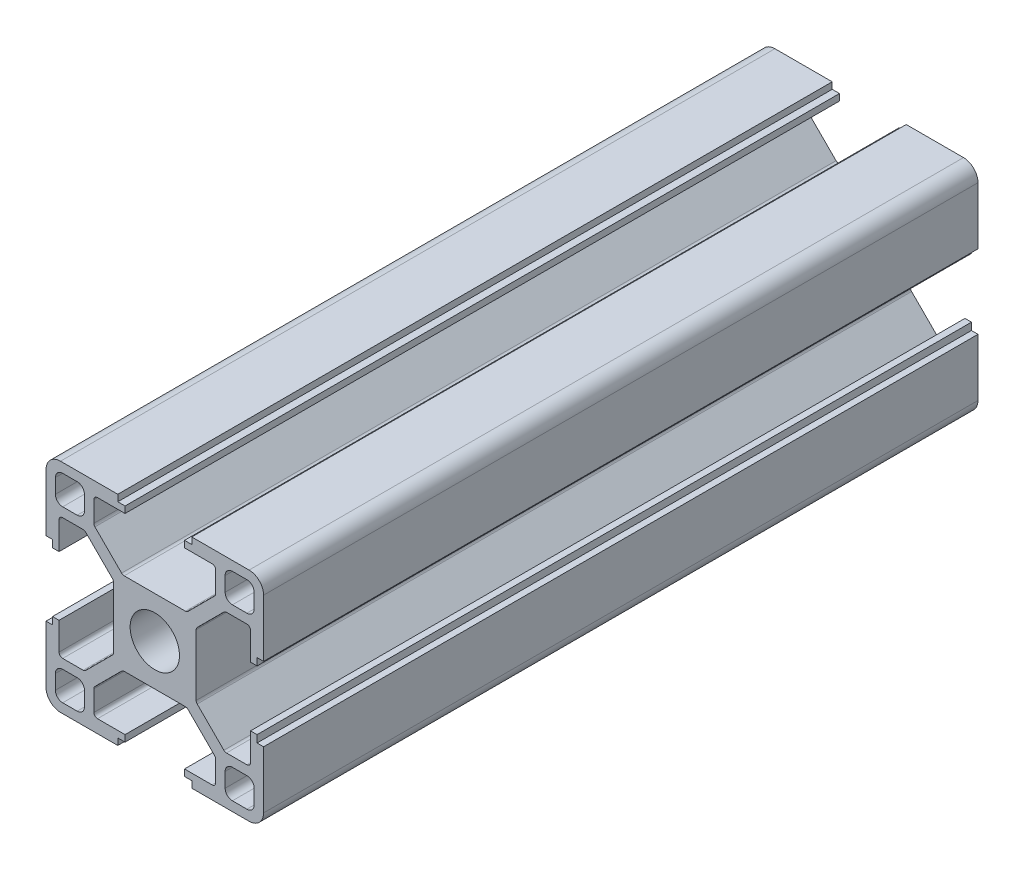
from build123d import *

# Parameters (mm, degrees)
SKETCH_1_W                       = 4
SKETCH_1_H                       = 4
EXTRUDE_1_DEPTH                  = 98.5
FILLET_1_R                       = 1
FILLET_2_R                       = 2
FILLET_3_R                       = 0.5
PATTERN_CIRCULAR_1_COUNT         = 4
FILLET_1_OF_PATTERN_CIRCULAR_1_R = 1
FILLET_2_OF_PATTERN_CIRCULAR_1_R = 2
FILLET_3_OF_PATTERN_CIRCULAR_1_R = 0.5
SKETCH_2_R                       = 3.4
CUT_EXTRUDE_1_DEPTH              = 99.5
SKETCH_3_R                       = 2.75
CUT_EXTRUDE_2_DEPTH              = 530


with BuildPart() as part:
    # 草图1 → 凸台-拉伸1 (new body)
    with BuildSketch(Plane.XY):
        Polygon((5.7, 0), (5.7, 4.427207794), (9.672792206, 8.4), (13.2, 8.4), (13.2, 4.1), (14.1, 4.1), (14.1, 5.1), (15, 5.1), (15, 15), (5.1, 15), (5.1, 14.1), (4.1, 14.1), (4.1, 13.2), (8.4, 13.2), (8.4, 9.672792206), (4.427207794, 5.7), (0, 5.7), (0, 0), align=None)
        with Locations((11.7, 11.7)):
            Rectangle(SKETCH_1_W, SKETCH_1_H, mode=Mode.SUBTRACT)
    extrude_1 = extrude(amount=EXTRUDE_1_DEPTH)

    # 圆角1
    fillet_1_edges = [part.edges().sort_by_distance(p)[0] for p in [
        (13.7, 9.7, 49.25),
        (13.7, 13.7, 49.25),
        (9.7, 13.7, 49.25),
        (9.7, 9.7, 49.25),
    ]]
    fillet(fillet_1_edges, radius=FILLET_1_R)

    # 圆角2
    fillet_2_edges = [part.edges().sort_by_distance(p)[0] for p in [
        (15, 15, 49.25),
    ]]
    fillet(fillet_2_edges, radius=FILLET_2_R)

    # 圆角3
    fillet_3_edges = [part.edges().sort_by_distance(p)[0] for p in [
        (4.427207794, 5.7, 49.25),
        (8.4, 9.672792206, 49.25),
        (8.4, 13.2, 49.25),
        (13.2, 8.4, 49.25),
        (9.672792206, 8.4, 49.25),
        (5.7, 4.427207794, 49.25),
    ]]
    fillet(fillet_3_edges, radius=FILLET_3_R)

    # 阵列(圆周)1: 凸台-拉伸1 ×4 about axis
    pattern_circular_1_axis = Axis((0, 0, 0), (0, 0, 1))
    for i in range(1, PATTERN_CIRCULAR_1_COUNT):
        add(extrude_1.rotate(pattern_circular_1_axis, i * 360 / PATTERN_CIRCULAR_1_COUNT))

    # 圆角1 of 阵列(圆周)1
    fillet_1_of_pattern_circular_1_edges = [part.edges().sort_by_distance(p)[0] for p in [
        (-9.7, 13.7, 49.25),
        (-13.7, 13.7, 49.25),
        (-13.7, 9.7, 49.25),
        (-9.7, 9.7, 49.25),
        (-13.7, -9.7, 49.25),
        (-13.7, -13.7, 49.25),
        (-9.7, -13.7, 49.25),
        (-9.7, -9.7, 49.25),
        (9.7, -13.7, 49.25),
        (13.7, -13.7, 49.25),
        (13.7, -9.7, 49.25),
        (9.7, -9.7, 49.25),
    ]]
    fillet(fillet_1_of_pattern_circular_1_edges, radius=FILLET_1_OF_PATTERN_CIRCULAR_1_R)

    # 圆角2 of 阵列(圆周)1
    fillet_2_of_pattern_circular_1_edges = [part.edges().sort_by_distance(p)[0] for p in [
        (-15, 15, 49.25),
        (-15, -15, 49.25),
        (15, -15, 49.25),
    ]]
    fillet(fillet_2_of_pattern_circular_1_edges, radius=FILLET_2_OF_PATTERN_CIRCULAR_1_R)

    # 圆角3 of 阵列(圆周)1
    fillet_3_of_pattern_circular_1_edges = [part.edges().sort_by_distance(p)[0] for p in [
        (-5.7, 4.427207794, 49.25),
        (-9.672792206, 8.4, 49.25),
        (-13.2, 8.4, 49.25),
        (-8.4, 13.2, 49.25),
        (-8.4, 9.672792206, 49.25),
        (-4.427207794, 5.7, 49.25),
        (-4.427207794, -5.7, 49.25),
        (-8.4, -9.672792206, 49.25),
        (-8.4, -13.2, 49.25),
        (-13.2, -8.4, 49.25),
        (-9.672792206, -8.4, 49.25),
        (-5.7, -4.427207794, 49.25),
        (5.7, -4.427207794, 49.25),
        (9.672792206, -8.4, 49.25),
        (13.2, -8.4, 49.25),
        (8.4, -13.2, 49.25),
        (8.4, -9.672792206, 49.25),
        (4.427207794, -5.7, 49.25),
    ]]
    fillet(fillet_3_of_pattern_circular_1_edges, radius=FILLET_3_OF_PATTERN_CIRCULAR_1_R)

    # 草图2 → 切除-拉伸1 (cut, through all)
    with BuildSketch(Plane.XY.offset(98.5)):
        Circle(SKETCH_2_R)
    extrude(amount=-CUT_EXTRUDE_1_DEPTH, mode=Mode.SUBTRACT)

    # 草图3 → 切除-拉伸2 (cut, symmetric)
    with BuildSketch(Plane(origin=(0, 0, 0), x_dir=(1, 0, 0), z_dir=(0, 1, 0))):
        with Locations((0, -58.5)):
            Circle(SKETCH_3_R)
        with Locations((0, -78.5)):
            Circle(SKETCH_3_R)
    extrude(amount=CUT_EXTRUDE_2_DEPTH, both=True, mode=Mode.SUBTRACT)


solid = part.part
